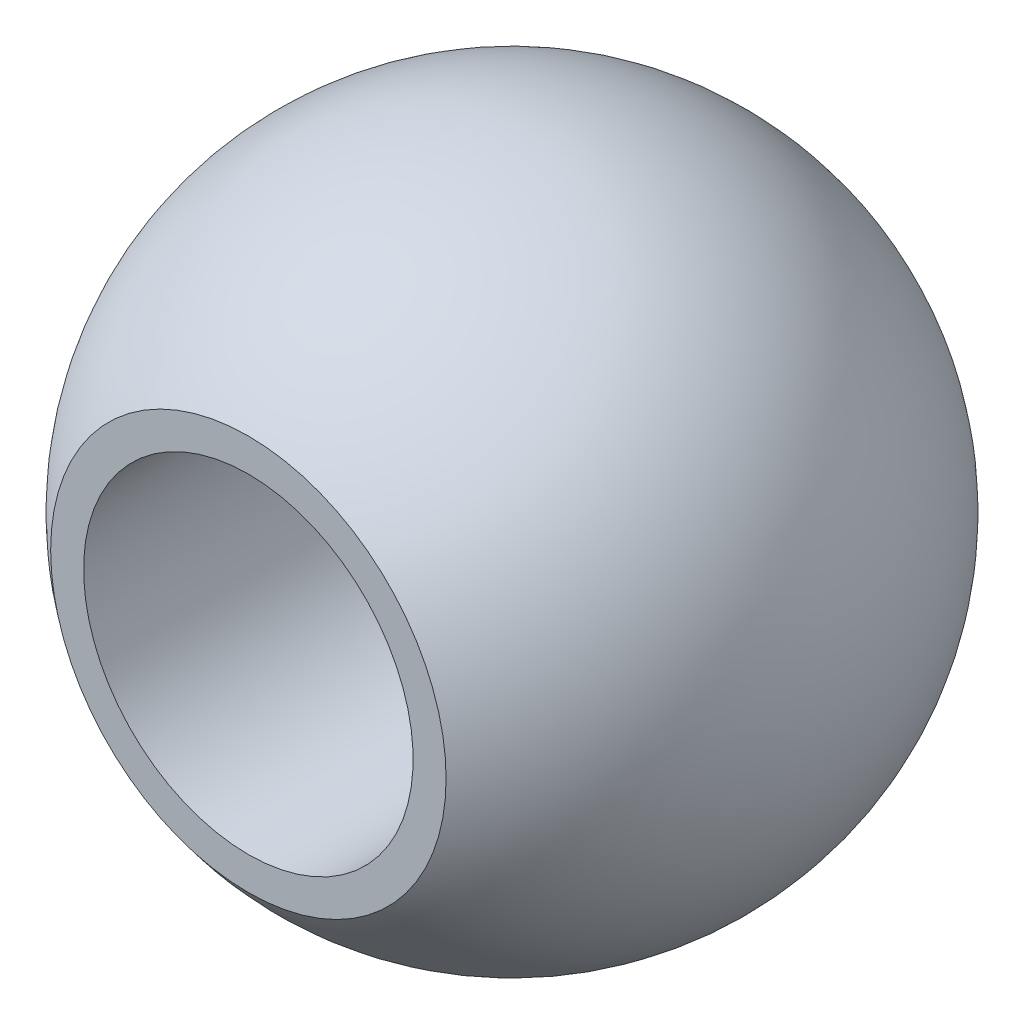
from build123d import *

# Parameters (mm, degrees)
WYTNIJ_WYCI_GNI_CIE1_DEPTH      = 10
WYTNIJ_WYCI_GNI_CIE1_DEPTH_BACK = 10
SZKIC2_R                        = 2.5
WYTNIJ_WYCI_GNI_CIE2_DEPTH      = 10
WYTNIJ_WYCI_GNI_CIE2_DEPTH_BACK = 10
SZKIC3_W                        = 2.429072565
SZKIC3_H                        = 11.30955291


with BuildPart() as part:
    # Szkic1 → Obrót1 (revolve)
    with BuildSketch(Plane.XY):
        with BuildLine():
            Line((0, 5), (0, -5))
            ThreePointArc((0, -5), (-5, 0), (0, 5))
        make_face()
    revolve(axis=Axis((0, 6.97442406, 0), (0, -1, 0)))

    # Szkic2 → Wytnij-wyciągnięcie1 (cut, two sides: drawn at the far end of the back side and taken through both)
    with BuildSketch(Plane.XY.offset(-WYTNIJ_WYCI_GNI_CIE1_DEPTH_BACK)):
        Circle(SZKIC2_R)
    extrude(amount=WYTNIJ_WYCI_GNI_CIE1_DEPTH + WYTNIJ_WYCI_GNI_CIE1_DEPTH_BACK, mode=Mode.SUBTRACT)

    # Szkic3 → Wytnij-wyciągnięcie2 (cut, two sides: drawn at the far end of the back side and taken through both)
    with BuildSketch(Plane(origin=(0, 0, 0), x_dir=(0, 0, -1), z_dir=(1, 0, 0)).offset(-WYTNIJ_WYCI_GNI_CIE2_DEPTH_BACK)):
        with Locations((5.214536283, -0.339547778)):
            Rectangle(SZKIC3_W, SZKIC3_H)
        with Locations((-5.214536283, -0.339547778)):
            Rectangle(SZKIC3_W, SZKIC3_H)
    extrude(amount=WYTNIJ_WYCI_GNI_CIE2_DEPTH + WYTNIJ_WYCI_GNI_CIE2_DEPTH_BACK, mode=Mode.SUBTRACT)


solid = part.part
